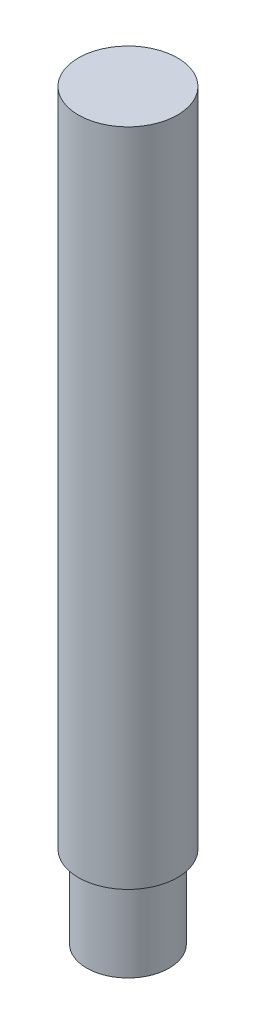
from build123d import *

# Parameters (mm, degrees)
SKETCH1_R           = 2.5
BOSS_EXTRUDE1_DEPTH = 5
BOSS_EXTRUDE2_START = 5
SKETCH1_4_R         = 3
BOSS_EXTRUDE2_DEPTH = 40


with BuildPart() as part:
    # Sketch1 → Boss-Extrude1 (new body)
    with BuildSketch(Plane(origin=(0, 0, 0), x_dir=(1, 0, 0), z_dir=(0, 1, 0))):
        Circle(SKETCH1_R)
    extrude(amount=BOSS_EXTRUDE1_DEPTH)

    # Sketch1_4 → Boss-Extrude2 (add)
    with BuildSketch(Plane(origin=(0, 0, 0), x_dir=(1, 0, 0), z_dir=(0, 1, 0)).offset(BOSS_EXTRUDE2_START)):
        Circle(SKETCH1_4_R)
    extrude(amount=BOSS_EXTRUDE2_DEPTH)


solid = part.part
